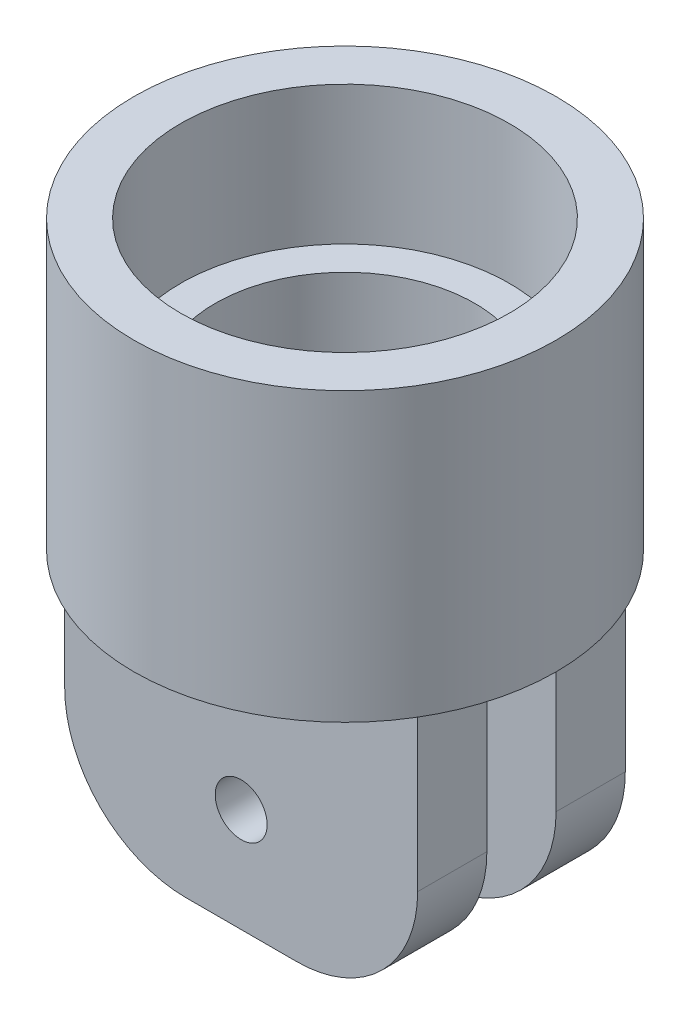
from build123d import *

# Parameters (mm, degrees)
SKETCH_1_R          = 6.1
EXTRUDE_1_DEPTH     = 8.3
SKETCH_2_R          = 4.75
CUT_EXTRUDE_1_DEPTH = 4
SKETCH_3_R          = 3.75
CUT_EXTRUDE_2_DEPTH = 3.5
SKETCH_4_R          = 1.5
CUT_EXTRUDE_3_DEPTH = 4
EXTRUDE_3_DEPTH     = 3
SKETCH_6_R          = 9.011135206
SKETCH_6_R_2        = 6.1
CUT_EXTRUDE_4_DEPTH = 32
SKETCH_7_R          = 0.5
CUT_EXTRUDE_6_DEPTH = 12
SKETCH_8_W          = 2
SKETCH_8_H          = 6.97178126
CUT_EXTRUDE_7_DEPTH = 10
SKETCH_9_W          = 7.844147965
SKETCH_9_H          = 6.877415643
CUT_EXTRUDE_8_DEPTH = 10
SKETCH_10_R         = 0.75
EXTRUDE_4_DEPTH     = 3
SKETCH_11_W         = 15.692438898
SKETCH_11_H         = 2
CUT_EXTRUDE_9_DEPTH = 8


with BuildPart() as part:
    # 草图1 → 凸台-拉伸1 (new body)
    with BuildSketch(Plane(origin=(0, 0, 0), x_dir=(1, 0, 0), z_dir=(0, 1, 0))):
        Circle(SKETCH_1_R)
    extrude(amount=EXTRUDE_1_DEPTH)

    # 草图2 → 切除-拉伸1 (cut)
    with BuildSketch(Plane(origin=(0, 8.3, 0), x_dir=(1, 0, 0), z_dir=(0, 1, 0))):
        Circle(SKETCH_2_R)
    extrude(amount=-CUT_EXTRUDE_1_DEPTH, mode=Mode.SUBTRACT)

    # 草图3 → 切除-拉伸2 (cut)
    with BuildSketch(Plane(origin=(0, 4.3, 0), x_dir=(1, 0, 0), z_dir=(0, 1, 0))):
        Circle(SKETCH_3_R)
    extrude(amount=-CUT_EXTRUDE_2_DEPTH, mode=Mode.SUBTRACT)

    # 草图4 → 切除-拉伸3 (cut)
    with BuildSketch(Plane(origin=(0, 0.8, 0), x_dir=(1, 0, 0), z_dir=(0, 1, 0))):
        Circle(SKETCH_4_R)
    extrude(amount=-CUT_EXTRUDE_3_DEPTH, mode=Mode.SUBTRACT)

    # 草图5 → 凸台-拉伸3 (add, symmetric)
    with BuildSketch(Plane.XY):
        with BuildLine():
            Line((-6.1, 0), (-2.1, 0))
            Line((-2.1, 0), (-2.1, -4.1))
            ThreePointArc((-2.1, -4.1), (-2.656497116, -5.443502884), (-4, -6))
            Line((-4, -6), (-4.2, -6))
            ThreePointArc((-4.2, -6), (-5.543502884, -5.443502884), (-6.1, -4.1))
            Line((-6.1, -4.1), (-6.1, 0))
        make_face()
    extrude(amount=EXTRUDE_3_DEPTH, both=True)

    # 草图6 → 切除-拉伸4 (cut)
    with BuildSketch(Plane(origin=(0, 8.3, 0), x_dir=(1, 0, 0), z_dir=(0, 1, 0))):
        Circle(SKETCH_6_R)
        Circle(SKETCH_6_R_2, mode=Mode.SUBTRACT)
    extrude(amount=-CUT_EXTRUDE_4_DEPTH, mode=Mode.SUBTRACT)

    # 草图7 → 切除-拉伸6 (cut)
    with BuildSketch(Plane.XY.offset(3)):
        with Locations((-4.1, -3.8)):
            Circle(SKETCH_7_R)
    extrude(amount=-CUT_EXTRUDE_6_DEPTH, mode=Mode.SUBTRACT)

    # 草图8 → 切除-拉伸7 (cut)
    with BuildSketch(Plane(origin=(-2.1, 0, 0), x_dir=(0, 0, -1), z_dir=(1, 0, 0))):
        with Locations((0, -3.48589063)):
            Rectangle(SKETCH_8_W, SKETCH_8_H)
    extrude(amount=-CUT_EXTRUDE_7_DEPTH, mode=Mode.SUBTRACT)

    # 草图9 → 切除-拉伸8 (cut)
    with BuildSketch(Plane(origin=(0, 0, -3), x_dir=(-1, 0, 0), z_dir=(0, 0, -1))):
        with Locations((6.022073983, -3.438707822)):
            Rectangle(SKETCH_9_W, SKETCH_9_H)
    extrude(amount=-CUT_EXTRUDE_8_DEPTH, mode=Mode.SUBTRACT)

    # 草图10 → 凸台-拉伸4 (add, symmetric)
    with BuildSketch(Plane.XY):
        with BuildLine():
            Line((-5.1, 0), (5.1, 0))
            Line((5.1, 0), (5.1, -4.5))
            ThreePointArc((5.1, -4.5), (4.074873734, -6.974873734), (1.6, -8))
            Line((1.6, -8), (-1.6, -8))
            ThreePointArc((-1.6, -8), (-4.074873734, -6.974873734), (-5.1, -4.5))
            Line((-5.1, -4.5), (-5.1, 0))
        make_face()
        with Locations((0, -5)):
            Circle(SKETCH_10_R, mode=Mode.SUBTRACT)
    extrude(amount=EXTRUDE_4_DEPTH, both=True)

    # 草图11 → 切除-拉伸9 (cut)
    with BuildSketch(Plane.XZ.offset(8)):
        with Locations((0.217533809, 0)):
            Rectangle(SKETCH_11_W, SKETCH_11_H)
    extrude(amount=-CUT_EXTRUDE_9_DEPTH, mode=Mode.SUBTRACT)


solid = part.part
